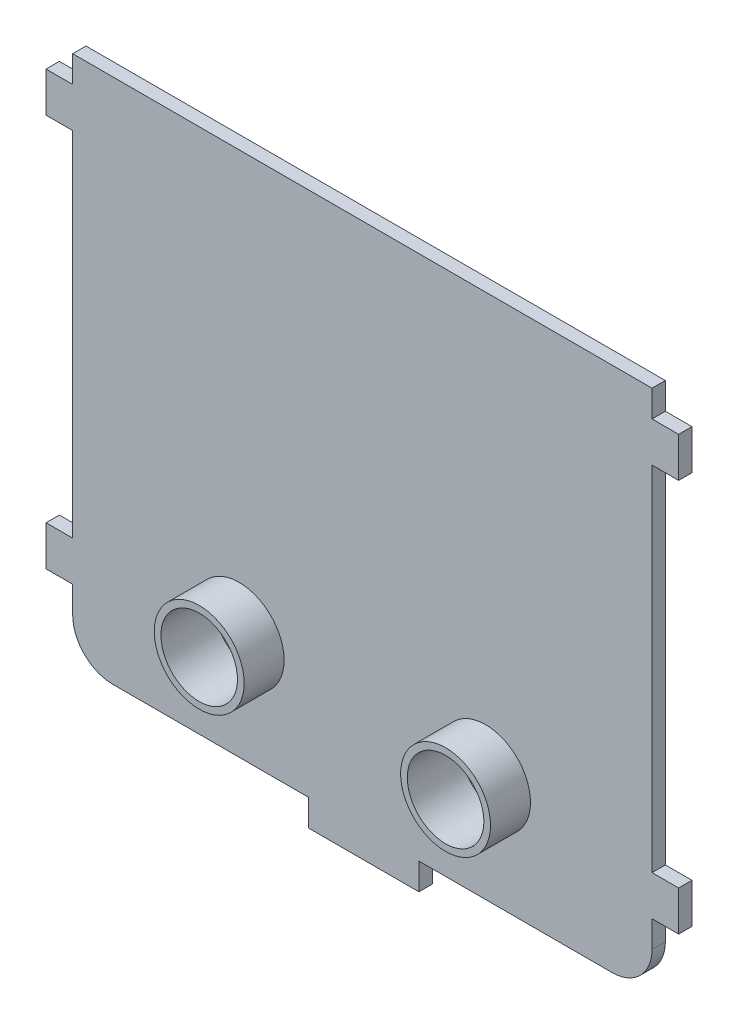
from build123d import *

# Parameters (mm, degrees)
SKETCH1_W            = 43.5
SKETCH1_H            = 39.5
BODY_DEPTH           = 1
SKETCH2_W            = 1
SKETCH2_H            = 3
CLIPS_R_DEPTH        = 2
SKETCH3_W            = 1
SKETCH3_H            = 3
CLIPS_L_DEPTH        = 2
SKETCH4_W            = 8.299556423
SKETCH4_H            = 1
CLIPS_B_DEPTH        = 2
SKETCH5_R            = 3.375
PADDLE_SUPPORT_DEPTH = 3
SKETCH6_R            = 2.875
BOLTS_DEPTH          = 5
FILLET1_R            = 3


with BuildPart() as part:
    # Sketch1 → body (new body)
    with BuildSketch(Plane.XY):
        Rectangle(SKETCH1_W, SKETCH1_H)
    extrude(amount=BODY_DEPTH)

    # Sketch2 → clips_r (add)
    with BuildSketch(Plane(origin=(21.75, 0, 0), x_dir=(0, 0, -1), z_dir=(1, 0, 0))):
        with Locations((-0.5, 16.25)):
            Rectangle(SKETCH2_W, SKETCH2_H)
        with Locations((-0.5, -13.25)):
            Rectangle(SKETCH2_W, SKETCH2_H)
    extrude(amount=CLIPS_R_DEPTH)

    # Sketch3 → clips_l (add)
    with BuildSketch(Plane.ZY.offset(21.75)):
        with Locations((0.5, -13.25)):
            Rectangle(SKETCH3_W, SKETCH3_H)
        with Locations((0.5, 16.25)):
            Rectangle(SKETCH3_W, SKETCH3_H)
    extrude(amount=CLIPS_L_DEPTH)

    # Sketch4 → clips_b (add)
    with BuildSketch(Plane.XZ.offset(19.75)):
        with Locations((0.100221788, 0.5)):
            Rectangle(SKETCH4_W, SKETCH4_H)
    extrude(amount=CLIPS_B_DEPTH)

    # Sketch5 → paddle_support (add)
    with BuildSketch(Plane.XY.offset(1)):
        with Locations((9.250464542, -11.75)):
            Circle(SKETCH5_R)
        with Locations((-9.250464542, -11.75)):
            Circle(SKETCH5_R)
    extrude(amount=PADDLE_SUPPORT_DEPTH)

    # Sketch6 → bolts (cut, through all)
    with BuildSketch(Plane.XY.offset(4)):
        with Locations((-9.250464542, -11.75)):
            Circle(SKETCH6_R)
        with Locations((9.250464542, -11.75)):
            Circle(SKETCH6_R)
    extrude(amount=-BOLTS_DEPTH, mode=Mode.SUBTRACT)

    # Fillet1
    fillet1_edges = [part.edges().sort_by_distance(p)[0] for p in [
        (21.75, -19.75, 0.5),
        (-21.75, -19.75, 0.5),
    ]]
    fillet(fillet1_edges, radius=FILLET1_R)


solid = part.part
